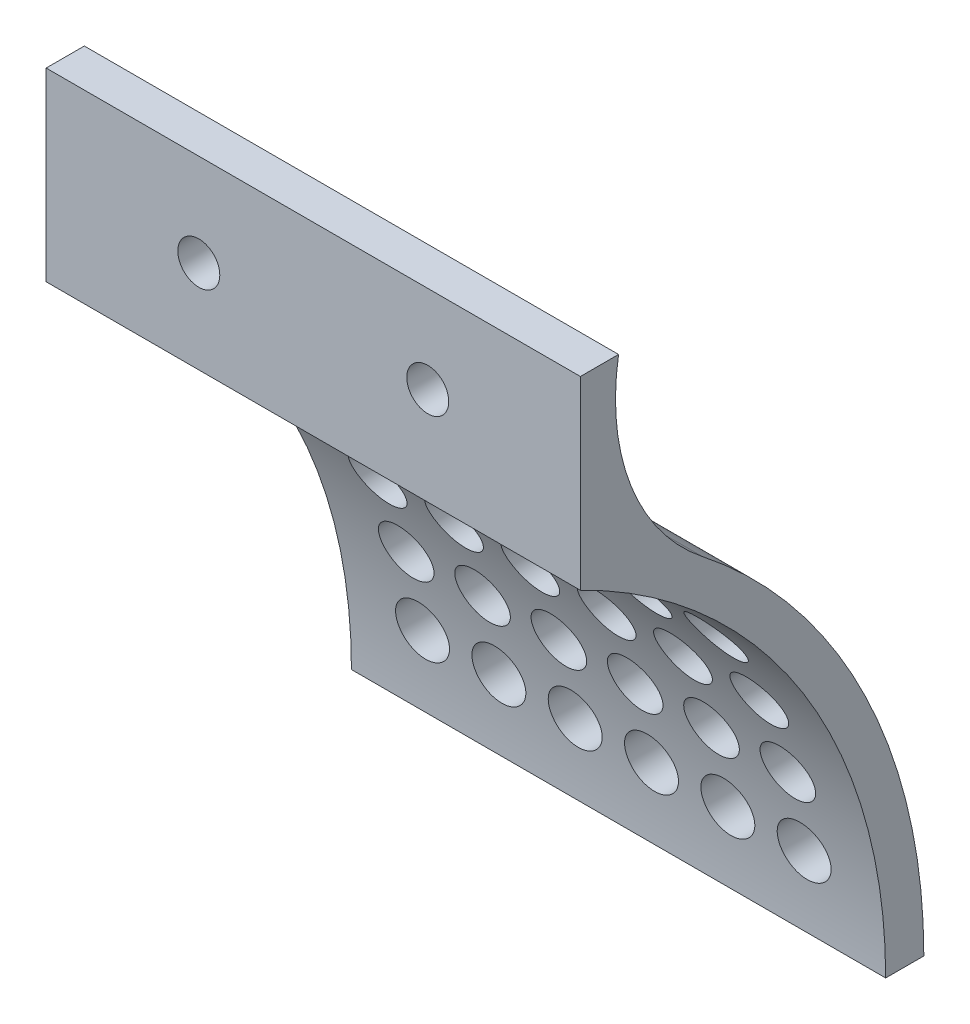
from build123d import *

# Parameters (mm, degrees)
SALIENTE_EXTRUIR1_DEPTH = 70
CROQUIS3_R              = 3.5
CORTAR_EXTRUIR3_DEPTH   = 65
CROQUIS2_R              = 2.750000002
CROQUIS2_R_2            = 2.75
CORTAR_EXTRUIR4_DEPTH   = 65


with BuildPart() as part:
    # Croquis1 → Saliente-Extruir1 (new body)
    with BuildSketch(Plane(origin=(0, 0, 0), x_dir=(0, 0, -1), z_dir=(1, 0, 0))):
        with BuildLine():
            Line((-25.193840863, 53.195024044), (-20.193840863, 53.195024044))
            ThreePointArc((-20.193840863, 53.195024044), (-18.573108699, 37.469004774), (-9.183016609, 24.750489713))
            ThreePointArc((-9.183016609, 24.750489713), (12.176943033, -1.828536951), (19.806159137, -35.062369049))
            Line((19.806159137, -35.062369049), (14.806159137, -35.062369049))
            ThreePointArc((14.806159137, -35.062369049), (3.983638383, 2.673555479), (-25.193840863, 28.937630951))
            Line((-25.193840863, 28.937630951), (-25.193840863, 53.195024044))
        make_face()
    extrude(amount=SALIENTE_EXTRUIR1_DEPTH)

    # Croquis3 → Cortar-Extruir3 (cut)
    with BuildSketch(Plane.XY.offset(-19.806159137)):
        with Locations((60, 14.750489713)):
            Circle(CROQUIS3_R)
        with Locations((50, 14.750489713)):
            Circle(CROQUIS3_R)
        with Locations((40, 14.750489713)):
            Circle(CROQUIS3_R)
        with Locations((30, 14.750489713)):
            Circle(CROQUIS3_R)
        with Locations((20, 14.750489713)):
            Circle(CROQUIS3_R)
        with Locations((10, 14.750489713)):
            Circle(CROQUIS3_R)
        with Locations((50, 4.750489713)):
            Circle(CROQUIS3_R)
        with Locations((40, 4.750489713)):
            Circle(CROQUIS3_R)
        with Locations((30, 4.750489713)):
            Circle(CROQUIS3_R)
        with Locations((20, 4.750489713)):
            Circle(CROQUIS3_R)
        with Locations((10, 4.750489713)):
            Circle(CROQUIS3_R)
        with Locations((50, -5.249510287)):
            Circle(CROQUIS3_R)
        with Locations((40, -5.249510287)):
            Circle(CROQUIS3_R)
        with Locations((30, -5.249510287)):
            Circle(CROQUIS3_R)
        with Locations((20, -5.249510287)):
            Circle(CROQUIS3_R)
        with Locations((10, -5.249510287)):
            Circle(CROQUIS3_R)
        with Locations((60, 4.750489713)):
            Circle(CROQUIS3_R)
        with Locations((60, -5.249510287)):
            Circle(CROQUIS3_R)
        with Locations((20, -15.249510287)):
            Circle(CROQUIS3_R)
        with Locations((30, -15.249510287)):
            Circle(CROQUIS3_R)
        with Locations((40, -15.249510287)):
            Circle(CROQUIS3_R)
        with Locations((50, -15.249510287)):
            Circle(CROQUIS3_R)
        with Locations((60, -15.249510287)):
            Circle(CROQUIS3_R)
        with Locations((20, -25.249510287)):
            Circle(CROQUIS3_R)
        with Locations((30, -25.249510287)):
            Circle(CROQUIS3_R)
        with Locations((40, -25.249510287)):
            Circle(CROQUIS3_R)
        with Locations((50, -25.249510287)):
            Circle(CROQUIS3_R)
        with Locations((60, -25.249510287)):
            Circle(CROQUIS3_R)
        with Locations((10, -15.249510287)):
            Circle(CROQUIS3_R)
        with Locations((10, -25.249510287)):
            Circle(CROQUIS3_R)
    extrude(amount=CORTAR_EXTRUIR3_DEPTH, mode=Mode.SUBTRACT)

    # Croquis2 → Cortar-Extruir4 (cut)
    with BuildSketch(Plane.XY.offset(25.193840863)):
        with Locations((20, 41.066327497)):
            Circle(CROQUIS2_R)
        with Locations((50, 41.717136777)):
            Circle(CROQUIS2_R_2)
    extrude(amount=-CORTAR_EXTRUIR4_DEPTH, mode=Mode.SUBTRACT)


solid = part.part
